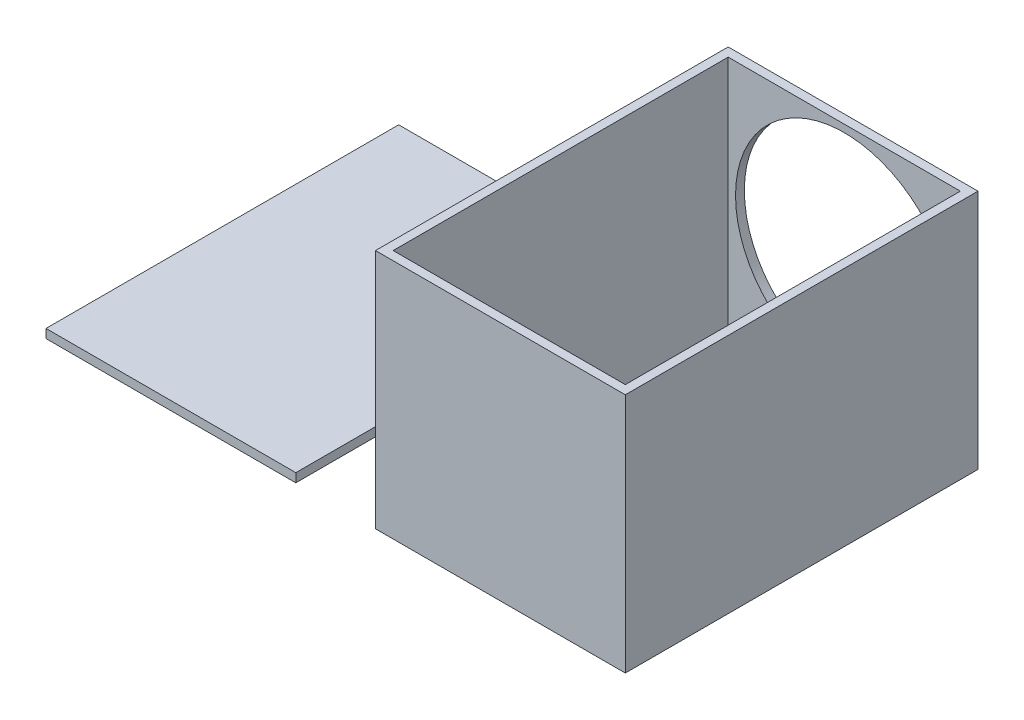
from build123d import *

# Parameters (mm, degrees)
SKETCH2_W           = 85
SKETCH2_H           = 82
SKETCH2_R           = 37
BOSS_EXTRUDE1_DEPTH = 3
SKETCH7_W           = 3
SKETCH7_H           = 82
BOSS_EXTRUDE2_DEPTH = 117
SKETCH8_W           = 82
SKETCH8_H           = 3
BOSS_EXTRUDE3_DEPTH = 117
SKETCH10_W          = 3
SKETCH10_H          = 79
BOSS_EXTRUDE4_DEPTH = 117
SKETCH11_W          = 79
SKETCH11_H          = 3
BOSS_EXTRUDE5_DEPTH = 79
SKETCH13_W          = 85
SKETCH13_H          = 3
BOSS_EXTRUDE6_DEPTH = 120


with BuildPart() as part:
    # Sketch2 → Boss-Extrude1 (new body)
    with BuildSketch(Plane.XY):
        with Locations((42.5, 41)):
            Rectangle(SKETCH2_W, SKETCH2_H)
        with Locations((42.5, 42.5)):
            Circle(SKETCH2_R, mode=Mode.SUBTRACT)
    extrude(amount=BOSS_EXTRUDE1_DEPTH)

    # Sketch7 → Boss-Extrude2 (add)
    with BuildSketch(Plane.XY.offset(3)):
        with Locations((1.5, 41)):
            Rectangle(SKETCH7_W, SKETCH7_H)
    extrude(amount=BOSS_EXTRUDE2_DEPTH)

    # Sketch8 → Boss-Extrude3 (add)
    with BuildSketch(Plane.XY.offset(3)):
        with Locations((44, 1.5)):
            Rectangle(SKETCH8_W, SKETCH8_H)
    extrude(amount=BOSS_EXTRUDE3_DEPTH)

    # Sketch10 → Boss-Extrude4 (add)
    with BuildSketch(Plane.XY.offset(3)):
        with Locations((83.5, 42.5)):
            Rectangle(SKETCH10_W, SKETCH10_H)
    extrude(amount=BOSS_EXTRUDE4_DEPTH)

    # Sketch11 → Boss-Extrude5 (add)
    with BuildSketch(Plane(origin=(0, 3, 0), x_dir=(1, 0, 0), z_dir=(0, 1, 0))):
        with Locations((42.5, -118.5)):
            Rectangle(SKETCH11_W, SKETCH11_H)
    extrude(amount=BOSS_EXTRUDE5_DEPTH)


with BuildPart() as body_2:
    # Sketch13 → Boss-Extrude6 (new body)
    with BuildSketch(Plane.XY):
        with Locations((-69.608594637, 1.5)):
            Rectangle(SKETCH13_W, SKETCH13_H)
    extrude(amount=BOSS_EXTRUDE6_DEPTH)


solid = Compound([part.part, body_2.part])
